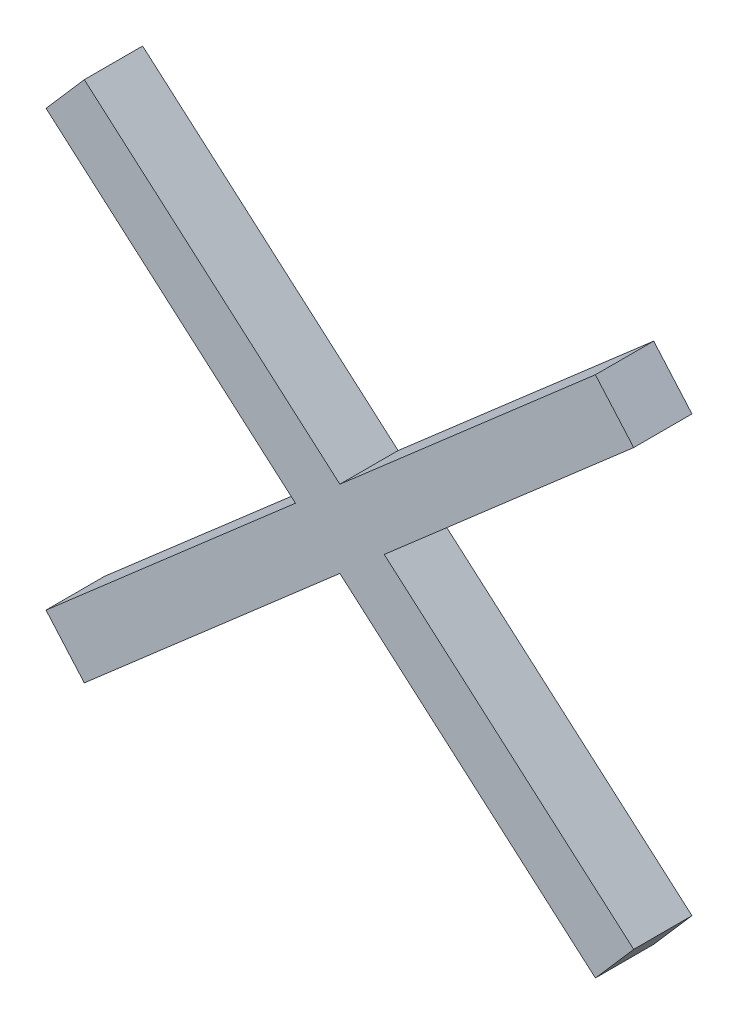
from build123d import *

# Parameters (mm, degrees)
BOSS_EXTRUDE1_DEPTH = 4


with BuildPart() as part:
    # Sketch1 → Boss-Extrude1 (new body)
    with BuildSketch(Plane.XY):
        Polygon((-20.165601387, 14.911355428), (-17.538478408, 17.927681812), (20.165601387, -14.911355428), (17.538478408, -17.927681812), align=None)
        Polygon((-17.538478408, -17.927681812), (-20.165601387, -14.911355428), (17.538478408, 17.927681812), (20.165601387, 14.911355428), align=None)
    extrude(amount=BOSS_EXTRUDE1_DEPTH)


solid = part.part
